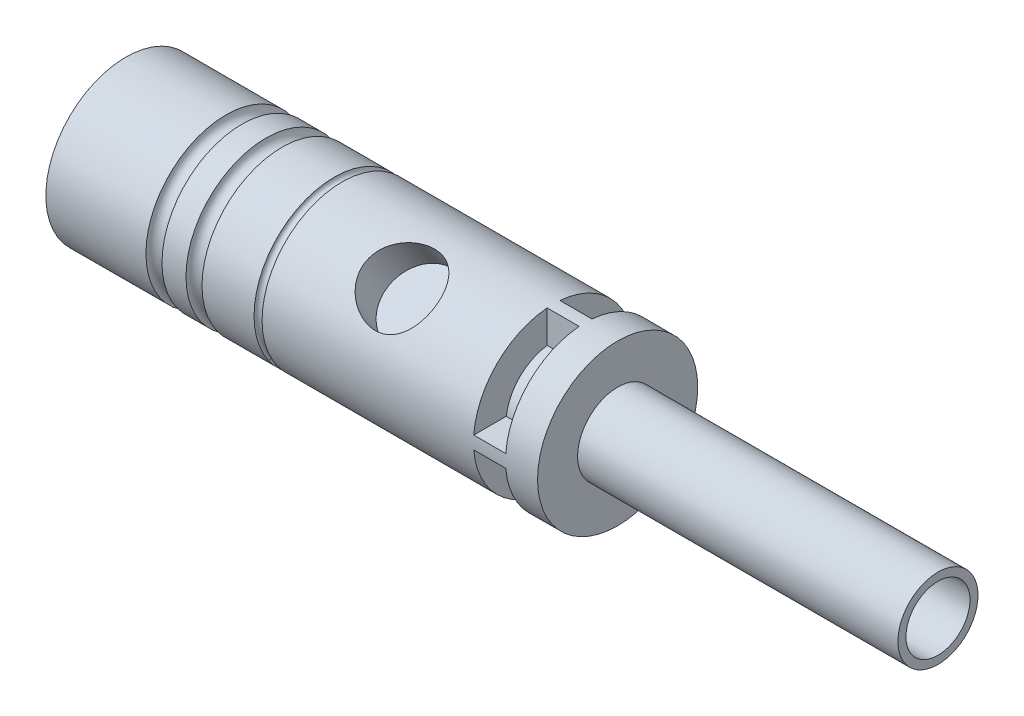
from build123d import *

# Parameters (mm, degrees)
SKETCH1_R           = 12.7
BOSS_EXTRUDE1_DEPTH = 38.989
SKETCH2_R           = 6.35
BOSS_EXTRUDE2_DEPTH = 50.8
SKETCH5_R           = 5.08
CUT_EXTRUDE1_DEPTH  = 50.8
SKETCH6_R           = 11.938
CUT_EXTRUDE2_DEPTH  = 11.684
SKETCH7_R           = 1.27
BOSS_EXTRUDE4_DEPTH = 6.35
SKETCH10_R          = 5.715
CUT_EXTRUDE3_DEPTH  = 7.62
SKETCH11_R          = 2.306564876
CUT_EXTRUDE4_DEPTH  = 18.674585575
CUT_EXTRUDE5_DEPTH  = 5.08
CIRPATTERN1_COUNT   = 4
SKETCH14_R          = 1.27
SKETCH14_R_2        = 0.635


with BuildPart() as part:
    # Sketch1 → Boss-Extrude1 (new body, symmetric)
    with BuildSketch(Plane(origin=(0, 0, 0), x_dir=(0, 0, -1), z_dir=(1, 0, 0))):
        Circle(SKETCH1_R)
    extrude(amount=BOSS_EXTRUDE1_DEPTH, both=True)

    # Sketch2 → Boss-Extrude2 (add)
    with BuildSketch(Plane(origin=(38.989, 0, 0), x_dir=(0, 0, -1), z_dir=(1, 0, 0))):
        Circle(SKETCH2_R)
    extrude(amount=BOSS_EXTRUDE2_DEPTH)

    # Sketch5 → Cut-Extrude1 (cut)
    with BuildSketch(Plane(origin=(89.789, 0, 0), x_dir=(0, 0, -1), z_dir=(1, 0, 0))):
        Circle(SKETCH5_R)
    extrude(amount=-CUT_EXTRUDE1_DEPTH, mode=Mode.SUBTRACT)

    # Sketch6 → Cut-Extrude2 (cut)
    with BuildSketch(Plane.ZY.offset(38.989)):
        Circle(SKETCH6_R)
    extrude(amount=-CUT_EXTRUDE2_DEPTH, mode=Mode.SUBTRACT)

    # Sketch7 → Boss-Extrude4 (add)
    with BuildSketch(Plane.ZY.offset(27.305)):
        Circle(SKETCH7_R)
    extrude(amount=BOSS_EXTRUDE4_DEPTH)

    # Sketch10 → Cut-Extrude3 (cut)
    with BuildSketch(Plane(origin=(0, 11.528802792, 8.001614114), x_dir=(1, 0, 0), z_dir=(0, 0.821520133, 0.570179507))):
        with Locations((11.73200505, 0)):
            Circle(SKETCH10_R)
    extrude(amount=-CUT_EXTRUDE3_DEPTH, mode=Mode.SUBTRACT)

    # Sketch11 → Cut-Extrude4 (cut, through all)
    with BuildSketch(Plane(origin=(0, 0, 0), x_dir=(1, 0, 0), z_dir=(0, -0.570179507, 0.821520133))):
        with Locations((16.023991034, 0)):
            Circle(SKETCH11_R)
        with Locations((-9.873377059, 0)):
            Circle(SKETCH11_R)
    extrude(amount=-CUT_EXTRUDE4_DEPTH, mode=Mode.SUBTRACT)

    # Sketch13 → Cut-Extrude5 (cut)
    with BuildSketch(Plane(origin=(33.909, 0, 0), x_dir=(0, 0, -1), z_dir=(1, 0, 0))):
        with BuildLine():
            Line((1.016, 7.50672894), (1.016, 13.505826979))
            ThreePointArc((1.016, 13.505826979), (9.577045953, 9.577045953), (13.505826979, 1.016))
            Line((13.505826979, 1.016), (7.50672894, 1.016))
            ThreePointArc((7.50672894, 1.016), (5.356455702, 5.356455702), (1.016, 7.50672894))
        make_face()
    cut_extrude5 = extrude(amount=-CUT_EXTRUDE5_DEPTH, mode=Mode.SUBTRACT)

    # CirPattern1: Cut-Extrude5 ×4 about axis
    cirpattern1_axis = Axis((0, 0, 0), (1, 0, 0))
    for i in range(1, CIRPATTERN1_COUNT):
        add(cut_extrude5.rotate(cirpattern1_axis, i * 360 / CIRPATTERN1_COUNT), mode=Mode.SUBTRACT)

    # Sketch14 → Cut-Revolve1 (revolve, cut)
    with BuildSketch(Plane.XY):
        with Locations((-21.844, 12.7)):
            Circle(SKETCH14_R)
        with Locations((-15.494, 12.7)):
            Circle(SKETCH14_R)
        with Locations((-5.334, 12.7)):
            Circle(SKETCH14_R_2)
    revolve(axis=Axis((-39.034342582, 0, 0), (1, 0, 0)), mode=Mode.SUBTRACT)


solid = part.part
